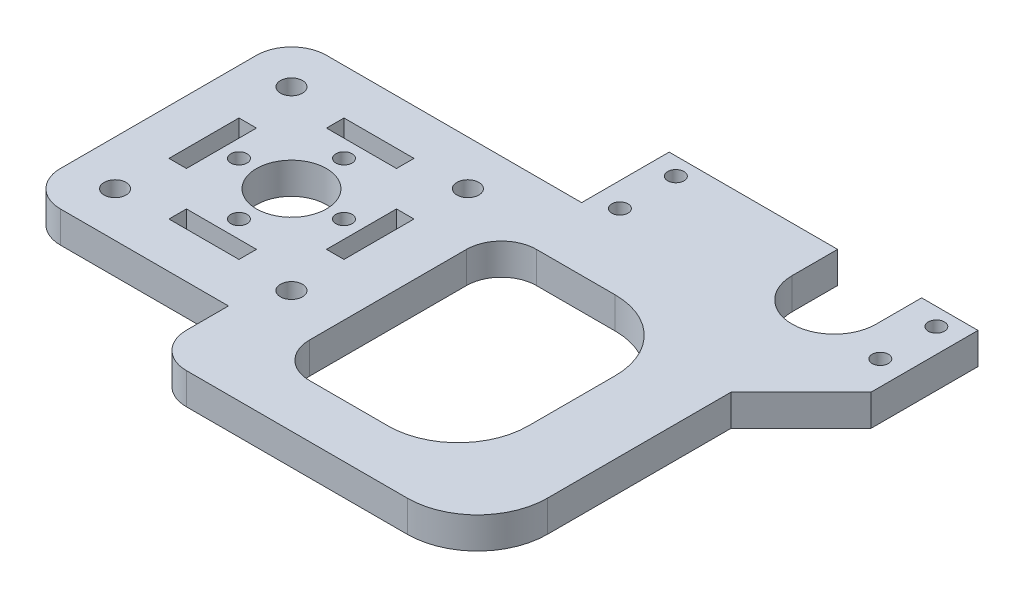
from build123d import *

# Parameters (mm, degrees)
SKETCH1_W                   = 33.3375
SKETCH1_H                   = 41.1861
BOSS_EXTRUDE1_DEPTH         = 5.6896
FILLET1_R                   = 12.7
FILLET2_R                   = 6.35
CUT_EXTRUDE3_REACH          = 7.69
SKETCH11_R                  = 6.35
SKETCH8_W                   = 12.7
SKETCH8_H                   = 3.175
CUT_EXTRUDE2_DEPTH          = 5.6896
F_4_CLEARANCE_HOLE3_D       = 2.9464
F_4_CLEARANCE_HOLE3_DEPTH   = 5.6906
CIRPATTERN1_COUNT           = 4
FILLET3_R                   = 12.7
F_4_CLEARANCE_HOLE4_D       = 2.9464
TAP_DRILL_FOR_4_HELICOIL1_D = 3.9878
FILLET4_R                   = 6.35


with BuildPart() as part:
    # Sketch1 → Boss-Extrude1 (new body)
    with BuildSketch(Plane(origin=(0, 0, 0), x_dir=(1, 0, 0), z_dir=(0, 1, 0))):
        with BuildLine():
            Line((28.4988, 40.005), (28.4988, 24.13))
            Line((28.4988, 24.13), (0, 24.13))
            Line((0, 24.13), (-24.13, 24.13))
            Line((-24.13, 24.13), (-24.13, 0))
            Line((-24.13, 0), (-24.13, -24.13))
            Line((-24.13, -24.13), (0, -24.13))
            Line((0, -24.13), (12.7, -24.13))
            Line((12.7, -24.13), (12.7, -38.1))
            Line((12.7, -38.1), (71.8185, -38.1))
            Line((71.8185, -38.1), (71.8185, 7.9375))
            Line((71.8185, 7.9375), (84.5185, 20.6375))
            Line((84.5185, 20.6375), (84.5185, 40.005))
            Line((84.5185, 40.005), (74.295, 40.005))
            Line((74.295, 40.005), (74.295, 31.75))
            ThreePointArc((74.295, 31.75), (66.675, 24.13), (59.055, 31.75))
            Line((59.055, 31.75), (59.055, 40.005))
            Line((59.055, 40.005), (28.4988, 40.005))
        make_face()
        with Locations((42.06875, -7.90575)):
            Rectangle(SKETCH1_W, SKETCH1_H, mode=Mode.SUBTRACT)
    extrude(amount=BOSS_EXTRUDE1_DEPTH)

    # Fillet1
    fillet1_edges = [part.edges().sort_by_distance(p)[0] for p in [
        (58.7375, 2.8448, 28.4988),
        (58.7375, 2.8448, -12.6873),
    ]]
    fillet(fillet1_edges, radius=FILLET1_R)

    # Fillet2
    fillet2_edges = [part.edges().sort_by_distance(p)[0] for p in [
        (25.4, 2.8448, -12.6873),
        (25.4, 2.8448, 28.4988),
    ]]
    fillet(fillet2_edges, radius=FILLET2_R)

    # Sketch11 → Cut-Extrude3 (cut, up to next)
    with BuildSketch(Plane(origin=(0, 5.6896, 0), x_dir=(1, 0, 0), z_dir=(0, 1, 0)), mode=Mode.PRIVATE) as cut_extrude3_sk1:
        Circle(SKETCH11_R)
    cut_extrude3_tool1 = extrude(cut_extrude3_sk1.sketch, amount=-CUT_EXTRUDE3_REACH, mode=Mode.PRIVATE) & part.part
    add(cut_extrude3_tool1.solids().sort_by_distance((0, 5.6896, 0))[0], mode=Mode.SUBTRACT)

    # Sketch8 → Cut-Extrude2 (cut)
    with BuildSketch(Plane(origin=(0, 5.6896, 0), x_dir=(1, 0, 0), z_dir=(0, 1, 0))):
        with Locations((0, 14.2875)):
            Rectangle(SKETCH8_W, SKETCH8_H)
    cut_extrude2 = extrude(amount=-CUT_EXTRUDE2_DEPTH, mode=Mode.SUBTRACT)

    # #4 Clearance Hole3
    with Locations(Plane(origin=(0, 5.6896, 0), x_dir=(1, 0, 0), z_dir=(0, 1, 0))):
        with Locations((0, 9.525)):
            f_4_clearance_hole3 = Hole(F_4_CLEARANCE_HOLE3_D / 2, depth=F_4_CLEARANCE_HOLE3_DEPTH)

    # CirPattern1: Cut-Extrude2, #4 Clearance Hole3 ×4 about axis
    cirpattern1_axis = Axis((0, 0, 0), (0, 1, 0))
    for i in range(1, CIRPATTERN1_COUNT):
        add(cut_extrude2.rotate(cirpattern1_axis, i * 360 / CIRPATTERN1_COUNT), mode=Mode.SUBTRACT)
        add(f_4_clearance_hole3.rotate(cirpattern1_axis, i * 360 / CIRPATTERN1_COUNT), mode=Mode.SUBTRACT)

    # Fillet3
    fillet3_edges = [part.edges().sort_by_distance(p)[0] for p in [
        (71.8185, 2.8448, 38.1),
    ]]
    fillet(fillet3_edges, radius=FILLET3_R)

    # #4 Clearance Hole4 (through all)
    with Locations(Plane(origin=(0, 5.6896, 0), x_dir=(1, 0, 0), z_dir=(0, 1, 0))):
        with Locations((32.893, 36.83), (80.137, 36.83), (80.137, 26.67), (32.893, 26.67)):
            Hole(F_4_CLEARANCE_HOLE4_D / 2)

    # Tap Drill for #4 Helicoil1 (through all)
    with Locations(Plane(origin=(0, 5.6896, 0), x_dir=(1, 0, 0), z_dir=(0, 1, 0))):
        with Locations((-15.998290924, 15.998290924), (15.998290924, -15.998290924), (15.998290924, 15.998290924), (-15.998290924, -15.998290924), (0, 0)):
            Hole(TAP_DRILL_FOR_4_HELICOIL1_D / 2)

    # Fillet4
    fillet4_edges = [part.edges().sort_by_distance(p)[0] for p in [
        (12.7, 2.8448, 38.1),
        (-24.13, 2.8448, 24.13),
        (-24.13, 2.8448, -24.13),
    ]]
    fillet(fillet4_edges, radius=FILLET4_R)


solid = part.part
